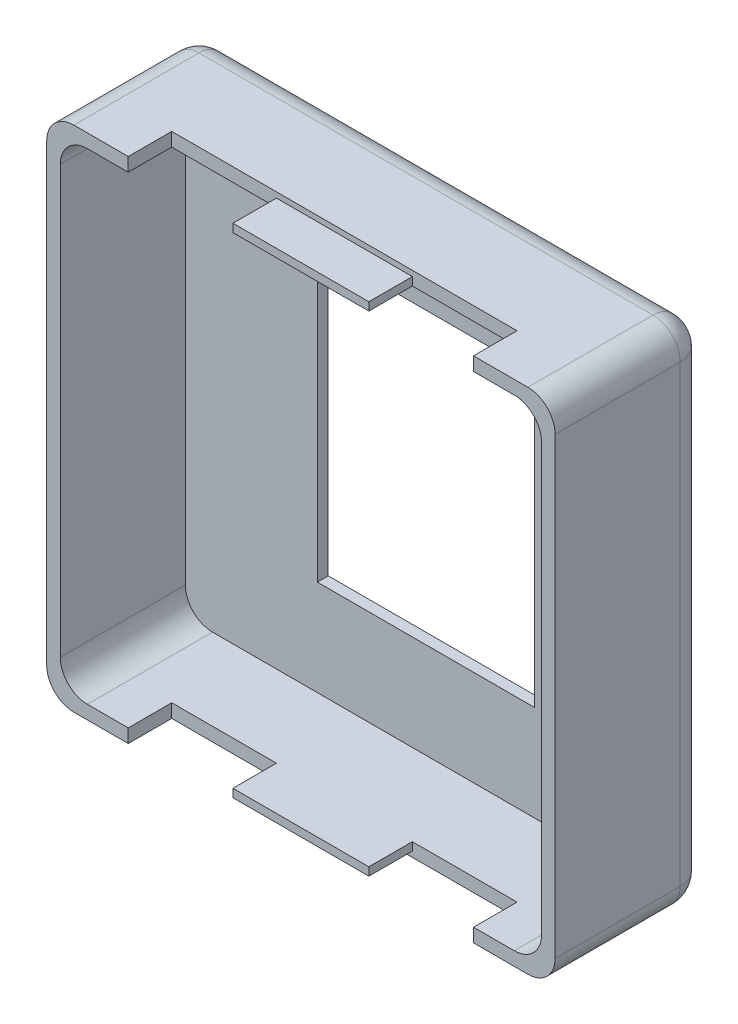
from build123d import *

# Parameters (mm, degrees)
BOSS_EXTRUDE1_DEPTH     = 14.224
CUT_EXTRUDE1_DEPTH      = 11.684
FILLET1_R               = 2.54
SKETCH3_W               = 32.258
SKETCH3_H               = 8.128
CUT_EXTRUDE2_DEPTH      = 1
CUT_EXTRUDE2_DEPTH_BACK = 48.498
SKETCH5_W               = 26.924
SKETCH5_H               = 34.29
CUT_EXTRUDE4_DEPTH      = 1.524
SKETCH6_W               = 20.290608306
SKETCH6_H               = 27.072145664
CUT_EXTRUDE5_DEPTH      = 1.524
BOSS_EXTRUDE2_DEPTH     = 0.762
SKETCH8_W               = 12.7
SKETCH8_H               = 0.762
BOSS_EXTRUDE3_DEPTH     = 4.064


with BuildPart() as part:
    # Sketch1 → Boss-Extrude1 (new body)
    with BuildSketch(Plane.XY):
        with BuildLine():
            Line((-21.209, -23.749), (21.209, -23.749))
            ThreePointArc((21.209, -23.749), (23.005051224, -23.005051224), (23.749, -21.209))
            Line((23.749, -21.209), (23.749, 21.209))
            ThreePointArc((23.749, 21.209), (23.005051224, 23.005051224), (21.209, 23.749))
            Line((21.209, 23.749), (-21.209, 23.749))
            ThreePointArc((-21.209, 23.749), (-23.005051224, 23.005051224), (-23.749, 21.209))
            Line((-23.749, 21.209), (-23.749, -21.209))
            ThreePointArc((-23.749, -21.209), (-23.005051224, -23.005051224), (-21.209, -23.749))
        make_face()
    extrude(amount=BOSS_EXTRUDE1_DEPTH)

    # Sketch2 → Cut-Extrude1 (cut)
    with BuildSketch(Plane.XY.offset(14.224)):
        with BuildLine():
            Line((19.939, -22.479), (-19.939, -22.479))
            ThreePointArc((-19.939, -22.479), (-21.735051224, -21.735051224), (-22.479, -19.939))
            Line((-22.479, -19.939), (-22.479, 19.939))
            ThreePointArc((-22.479, 19.939), (-21.735051224, 21.735051224), (-19.939, 22.479))
            Line((-19.939, 22.479), (19.939, 22.479))
            ThreePointArc((19.939, 22.479), (21.735051224, 21.735051224), (22.479, 19.939))
            Line((22.479, 19.939), (22.479, -19.939))
            ThreePointArc((22.479, -19.939), (21.735051224, -21.735051224), (19.939, -22.479))
        make_face()
    extrude(amount=-CUT_EXTRUDE1_DEPTH, mode=Mode.SUBTRACT)

    # Fillet1
    fillet1_edges = [part.edges().sort_by_distance(p)[0] for p in [
        (0, -23.749, 0),
        (-23.005051224, -23.005051224, 0),
        (-23.749, 0, 0),
        (-23.005051224, 23.005051224, 0),
        (0, 23.749, 0),
        (23.005051224, 23.005051224, 0),
        (23.749, 0, 0),
        (23.005051224, -23.005051224, 0),
    ]]
    fillet(fillet1_edges, radius=FILLET1_R)

    # Sketch3 → Cut-Extrude2 (cut, two sides)
    with BuildSketch(Plane(origin=(0, 23.749, 0), x_dir=(1, 0, 0), z_dir=(0, 1, 0))) as cut_extrude2_sk:
        with Locations((0, -14.224)):
            Rectangle(SKETCH3_W, SKETCH3_H)
    extrude(amount=CUT_EXTRUDE2_DEPTH, mode=Mode.SUBTRACT)
    extrude(cut_extrude2_sk.sketch, amount=-CUT_EXTRUDE2_DEPTH_BACK, mode=Mode.SUBTRACT)

    # Sketch5 → Cut-Extrude4 (cut)
    with BuildSketch(Plane(origin=(0, 0, 0), x_dir=(-1, 0, 0), z_dir=(0, 0, -1))):
        Rectangle(SKETCH5_W, SKETCH5_H)
    extrude(amount=-CUT_EXTRUDE4_DEPTH, mode=Mode.SUBTRACT)

    # Sketch6 → Cut-Extrude5 (cut)
    with BuildSketch(Plane(origin=(0, 0, 1.524), x_dir=(-1, 0, 0), z_dir=(0, 0, -1))):
        Rectangle(SKETCH6_W, SKETCH6_H)
    extrude(amount=-CUT_EXTRUDE5_DEPTH, mode=Mode.SUBTRACT)

    # Sketch7 → Boss-Extrude2 (add)
    with BuildSketch(Plane(origin=(0, 0, 0), x_dir=(-1, 0, 0), z_dir=(0, 0, -1))):
        with BuildLine():
            Line((19.939, 17.145), (21.209, 17.145))
            ThreePointArc((21.209, 17.145), (17.399, 20.955), (13.589, 17.145))
            Line((13.589, 17.145), (14.859, 17.145))
            ThreePointArc((14.859, 17.145), (17.399, 19.685), (19.939, 17.145))
        make_face()
        with BuildLine():
            Line((21.209, 15.875), (16.129, 15.875))
            ThreePointArc((16.129, 15.875), (13.589, 13.335), (16.129, 10.795))
            Line((16.129, 10.795), (21.209, 10.795))
            Line((21.209, 10.795), (21.209, 12.065))
            Line((21.209, 12.065), (16.129, 12.065))
            ThreePointArc((16.129, 12.065), (14.859, 13.335), (16.129, 14.605))
            Line((16.129, 14.605), (21.209, 14.605))
            Line((21.209, 14.605), (21.209, 15.875))
        make_face()
        Polygon((13.589, 9.525), (21.209, 9.525), (21.209, 5.715), (19.939, 5.715), (19.939, 8.255), (18.034, 8.255), (18.034, 6.985), (16.764, 6.985), (16.764, 8.255), (13.589, 8.255), align=None)
        Polygon((13.589, 4.445), (21.209, 4.445), (21.209, 0.635), (19.939, 0.635), (19.939, 3.175), (18.034, 3.175), (18.034, 1.905), (16.764, 1.905), (16.764, 3.175), (13.589, 3.175), align=None)
        Polygon((21.209, -0.635), (13.589, -0.635), (13.589, -4.445), (14.859, -4.445), (14.859, -1.905), (21.209, -1.905), align=None)
        Polygon((13.589, -5.715), (21.209, -5.715), (21.209, -9.525), (19.939, -9.525), (19.939, -6.985), (18.034, -6.985), (18.034, -8.255), (16.764, -8.255), (16.764, -6.985), (14.859, -6.985), (14.859, -9.525), (13.589, -9.525), align=None)
        with BuildLine():
            Line((18.9865, -13.97), (18.9865, -15.24))
            ThreePointArc((18.9865, -15.24), (20.558044821, -11.445955179), (16.764, -13.0175))
            ThreePointArc((16.764, -13.0175), (15.137980791, -13.691019209), (15.8115, -12.065))
            Line((15.8115, -12.065), (15.8115, -10.795))
            ThreePointArc((15.8115, -10.795), (14.239955179, -14.589044821), (18.034, -13.0175))
            ThreePointArc((18.034, -13.0175), (19.660019209, -12.343980791), (18.9865, -13.97))
        make_face()
        with BuildLine():
            Line((15.8115, -17.78), (15.8115, -16.51))
            ThreePointArc((15.8115, -16.51), (14.239955179, -20.304044821), (18.034, -18.7325))
            ThreePointArc((18.034, -18.7325), (19.660019209, -18.058980791), (18.9865, -19.685))
            Line((18.9865, -19.685), (18.9865, -20.955))
            ThreePointArc((18.9865, -20.955), (20.558044821, -17.160955179), (16.764, -18.7325))
            ThreePointArc((16.764, -18.7325), (15.137980791, -19.406019209), (15.8115, -17.78))
        make_face()
    extrude(amount=BOSS_EXTRUDE2_DEPTH)

    # Sketch8 → Boss-Extrude3 (add)
    with BuildSketch(Plane.XY.offset(10.16)):
        with Locations((0, 22.86)):
            Rectangle(SKETCH8_W, SKETCH8_H)
        with Locations((0, -22.86)):
            Rectangle(SKETCH8_W, SKETCH8_H)
    extrude(amount=BOSS_EXTRUDE3_DEPTH)


solid = part.part
